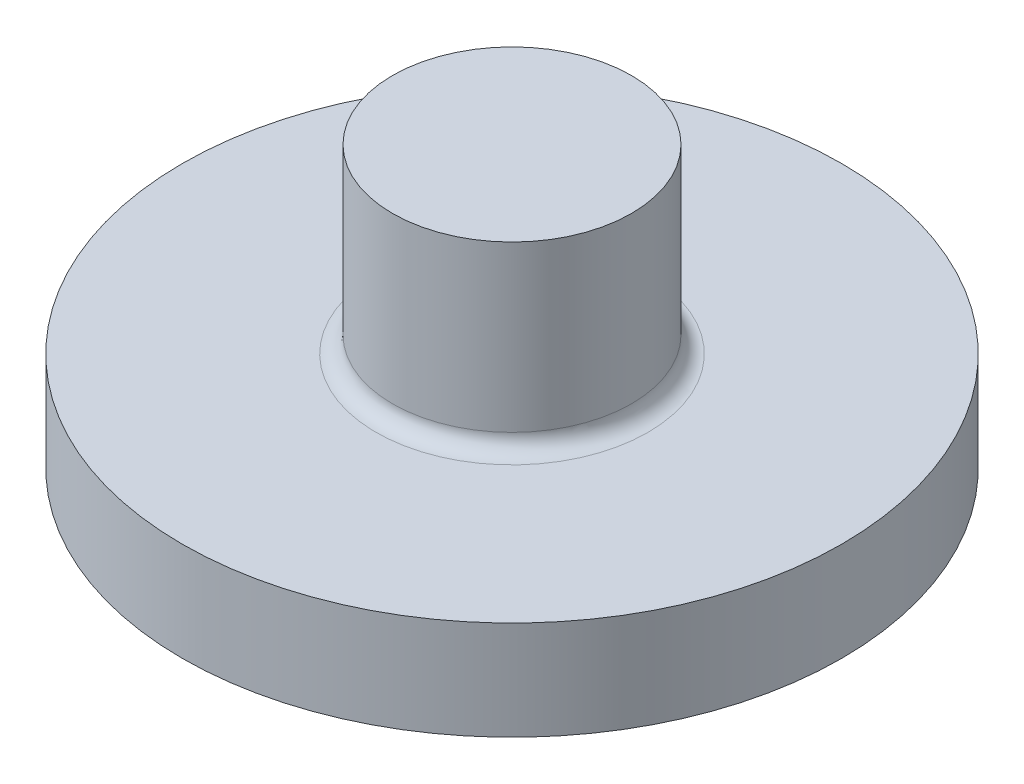
from build123d import *

# Parameters (mm, degrees)
FILLET1_R = 0.1


with BuildPart() as part:
    # Sketch1 → Revolve1 (revolve)
    with BuildSketch(Plane.XY, mode=Mode.PRIVATE) as revolve1_sk:
        Polygon((0, 1.7), (0.725, 1.7), (0.725, 0.6), (2, 0.6), (2, 0), (0, 0), align=None)
    revolve(revolve1_sk.sketch.rotate(Axis((0, 48.181694323, 0), (0, -1, 0)), 180), axis=Axis((0, 48.181694323, 0), (0, -1, 0)))  # turned: the seam where the file's is

    # Fillet1
    fillet1_edges = [part.edges().sort_by_distance(p)[0] for p in [
        (0.725, 0.6, 0),
    ]]
    fillet(fillet1_edges, radius=FILLET1_R)


solid = part.part
